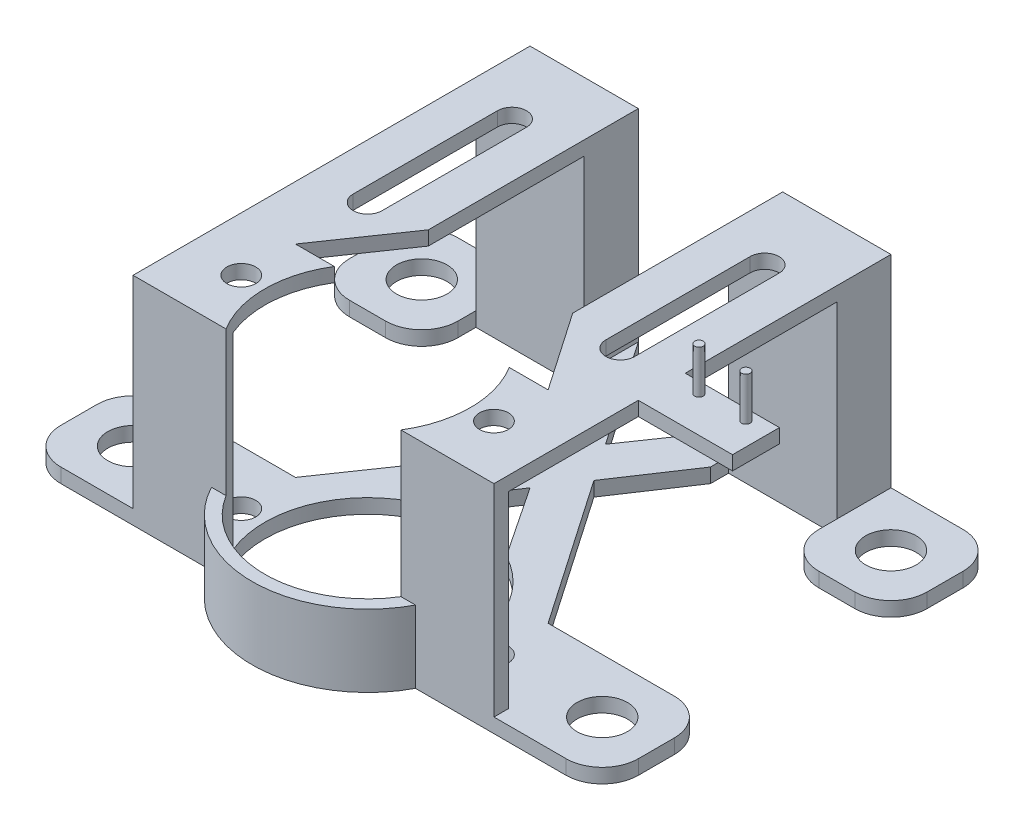
from build123d import *

# Parameters (mm, degrees)
SKETCH1_R             = 2
BOSS_EXTRUDE3_DEPTH   = 30
BOSS_EXTRUDE3_2_DEPTH = 30
SKETCH1_6_W           = 15
SKETCH1_6_H           = 15
SKETCH1_6_R           = 3.5
BOSS_EXTRUDE5_DEPTH   = 2
BOSS_EXTRUDE7_DEPTH   = 30
BOSS_EXTRUDE8_DEPTH   = 30
SKETCH6_W             = 28.26658805
SKETCH6_H             = 20
CUT_EXTRUDE2_DEPTH    = 9
SKETCH1_11_R          = 0.6
BOSS_EXTRUDE9_DEPTH   = 36
BOSS_EXTRUDE9_2_DEPTH = 36
SKETCH1_12_R          = 0.6
BOSS_EXTRUDE10_DEPTH  = 30
SKETCH8_W             = 13.05
SKETCH8_H             = 28.046654986
CUT_EXTRUDE3_DEPTH    = 7
CUT_EXTRUDE8_DEPTH    = 50
FILLET2_R             = 5
SKETCH11_W            = 12.973509336
SKETCH11_H            = 26.046654986
CUT_EXTRUDE9_DEPTH    = 52
BOSS_EXTRUDE11_DEPTH  = 2


with BuildPart() as part:
    # Sketch1 → Boss-Extrude3 (new body)
    with BuildSketch(Plane(origin=(0, 0, 0), x_dir=(1, 0, 0), z_dir=(0, 1, 0))):
        with BuildLine():
            Line((-15, 0), (-2.116620816, 0))
            ThreePointArc((-2.116620816, 0), (-3.706282257, 3.601240366), (-4.25, 7.5))
            ThreePointArc((-4.25, 7.5), (-3.706282257, 11.398759634), (-2.116620816, 15))
            Line((-2.116620816, 15), (-7.5, 15))
            Line((-7.5, 15), (0, 25.909090909))
            Line((0, 25.909090909), (0, 55))
            Line((0, 55), (-15, 55))
            Line((-15, 55), (-15, 0))
        make_face()
        with Locations((-7.5, 7.5)):
            Circle(SKETCH1_R, mode=Mode.SUBTRACT)
        with BuildLine():
            ThreePointArc((-9.5, 45), (-7.5, 47), (-5.5, 45))
            Line((-5.5, 45), (-5.5, 25))
            ThreePointArc((-5.5, 25), (-7.5, 23), (-9.5, 25))
            Line((-9.5, 25), (-9.5, 45))
        make_face(mode=Mode.SUBTRACT)
    extrude(amount=BOSS_EXTRUDE3_DEPTH)



with BuildPart() as body_2:
    # Sketch1 → Boss-Extrude3 2 (new body)
    with BuildSketch(Plane(origin=(0, 0, 0), x_dir=(1, 0, 0), z_dir=(0, 1, 0))):
        with BuildLine():
            ThreePointArc((22.116620816, 15), (23.706282257, 11.398759634), (24.25, 7.5))
            Line((24.25, 7.5), (25.5, 7.5))
            ThreePointArc((25.5, 7.5), (27.5, 9.5), (29.5, 7.5))
            Line((29.5, 7.5), (35, 7.5))
            Line((35, 7.5), (35, 55))
            Line((35, 55), (20, 55))
            Line((20, 55), (20, 25.909090909))
            Line((20, 25.909090909), (27.5, 15))
            Line((27.5, 15), (22.116620816, 15))
        make_face()
        with BuildLine():
            ThreePointArc((29.5, 25), (27.5, 23), (25.5, 25))
            Line((25.5, 25), (25.5, 45))
            ThreePointArc((25.5, 45), (27.5, 47), (29.5, 45))
            Line((29.5, 45), (29.5, 25))
        make_face(mode=Mode.SUBTRACT)
    extrude(amount=BOSS_EXTRUDE3_2_DEPTH)


with BuildPart() as part_1:
    add(part.part)

    add(body_2.part)  # Boss-Extrude5 merges body 2
    # Sketch1_6 → Boss-Extrude5 (add)
    # profile 1 of 4: a face of its own
    with BuildSketch(Plane(origin=(0, 0, 0), x_dir=(1, 0, 0), z_dir=(0, 1, 0))):
        with Locations((-22.5, 7.5)):
            Rectangle(SKETCH1_6_W, SKETCH1_6_H)
        with Locations((-22.5, 7.5)):
            Circle(SKETCH1_6_R, mode=Mode.SUBTRACT)
    # profile 2 of 4: a face of its own
    with BuildSketch(Plane(origin=(0, 0, 0), x_dir=(1, 0, 0), z_dir=(0, 1, 0))):
        with Locations((42.5, 7.5)):
            Rectangle(SKETCH1_6_W, SKETCH1_6_H)
        with Locations((42.5, 7.5)):
            Circle(SKETCH1_6_R, mode=Mode.SUBTRACT)
    # profile 3 of 4: a face of its own
    with BuildSketch(Plane(origin=(0, 0, 0), x_dir=(1, 0, 0), z_dir=(0, 1, 0))):
        with Locations((-22.5, 47.5)):
            Rectangle(SKETCH1_6_W, SKETCH1_6_H)
        with Locations((-22.5, 47.5)):
            Circle(SKETCH1_6_R, mode=Mode.SUBTRACT)
    # profile 4 of 4: a face of its own
    with BuildSketch(Plane(origin=(0, 0, 0), x_dir=(1, 0, 0), z_dir=(0, 1, 0))):
        with Locations((42.5, 47.5)):
            Rectangle(SKETCH1_6_W, SKETCH1_6_H)
        with Locations((42.5, 47.5)):
            Circle(SKETCH1_6_R, mode=Mode.SUBTRACT)
    extrude(amount=BOSS_EXTRUDE5_DEPTH)

    # Sketch1_8 → Boss-Extrude7 (add)
    with BuildSketch(Plane(origin=(0, 0, 0), x_dir=(1, 0, 0), z_dir=(0, 1, 0))):
        with BuildLine():
            Line((-2.116620816, 0), (-4.133294025, 0))
            ThreePointArc((-4.133294025, 0), (1.753788749, -6.211309201), (10, -8.5))
            ThreePointArc((10, -8.5), (18.246211251, -6.211309201), (24.133294025, 0))
            Line((24.133294025, 0), (22.116620816, 0))
            ThreePointArc((22.116620816, 0), (10, -6.75), (-2.116620816, 0))
        make_face()
    extrude(amount=BOSS_EXTRUDE7_DEPTH)

    # Sketch1_9 → Boss-Extrude8 (add)
    with BuildSketch(Plane(origin=(0, 0, 0), x_dir=(1, 0, 0), z_dir=(0, 1, 0))):
        with BuildLine():
            ThreePointArc((24.25, 7.5), (23.706282257, 3.601240366), (22.116620816, 0))
            Line((22.116620816, 0), (24.133294025, 0))
            Line((24.133294025, 0), (35, 0))
            Line((35, 0), (35, 7.5))
            Line((35, 7.5), (29.5, 7.5))
            ThreePointArc((29.5, 7.5), (27.5, 5.5), (25.5, 7.5))
            Line((25.5, 7.5), (24.25, 7.5))
        make_face()
    extrude(amount=BOSS_EXTRUDE8_DEPTH)

    # Sketch6 → Cut-Extrude2 (cut)
    with BuildSketch(Plane.XY):
        with Locations((10, 20)):
            Rectangle(SKETCH6_W, SKETCH6_H)
    extrude(amount=CUT_EXTRUDE2_DEPTH, mode=Mode.SUBTRACT)



with BuildPart() as body_2_2:
    # Sketch1_11 → Boss-Extrude9 (new body)
    with BuildSketch(Plane(origin=(0, 0, 0), x_dir=(1, 0, 0), z_dir=(0, 1, 0))):
        with Locations((44.9, 25)):
            Circle(SKETCH1_11_R)
    extrude(amount=BOSS_EXTRUDE9_DEPTH)


with BuildPart() as body_3:
    # Sketch1_11 → Boss-Extrude9 2 (new body)
    with BuildSketch(Plane(origin=(0, 0, 0), x_dir=(1, 0, 0), z_dir=(0, 1, 0))):
        with Locations((38.4, 25)):
            Circle(SKETCH1_11_R)
    extrude(amount=BOSS_EXTRUDE9_2_DEPTH)


with BuildPart() as part_2:
    add(part_1.part)

    add(body_2_2.part)  # Boss-Extrude10 merges body 2 2

    add(body_3.part)  # Boss-Extrude10 merges body 3
    # Sketch1_12 → Boss-Extrude10 (add)
    with BuildSketch(Plane(origin=(0, 0, 0), x_dir=(1, 0, 0), z_dir=(0, 1, 0))):
        Polygon((35, 26.5), (35, 20), (48.05, 20), (48.05, 26.5), (38.4, 26.5), align=None)
        with BuildLine():
            ThreePointArc((39, 25), (37.975735931, 24.575735931), (38.4, 25.6))
            ThreePointArc((38.4, 25.6), (38.824264069, 25.424264069), (39, 25))
        make_face(mode=Mode.SUBTRACT)
        with Locations((44.9, 25)):
            Circle(SKETCH1_12_R, mode=Mode.SUBTRACT)
    extrude(amount=BOSS_EXTRUDE10_DEPTH)

    # Sketch8 → Cut-Extrude3 (cut)
    with BuildSketch(Plane.XY.offset(-20)):
        with Locations((41.525, 14.023327493)):
            Rectangle(SKETCH8_W, SKETCH8_H)
    extrude(amount=-CUT_EXTRUDE3_DEPTH, mode=Mode.SUBTRACT)

    # Sketch10 → Cut-Extrude8 (cut)
    with BuildSketch(Plane(origin=(35, 0, 0), x_dir=(0, 0, -1), z_dir=(1, 0, 0))):
        Polygon((15, 2), (15, 0), (40, 0), (47.5, 0), (47.5, 28.046654986), (15, 28.046654986), align=None)
    extrude(amount=-CUT_EXTRUDE8_DEPTH, mode=Mode.SUBTRACT)

    # Fillet2
    fillet2_edges = [part_2.edges().sort_by_distance(p)[0] for p in [
        (-30, 1, -15),
        (-30, 1, -40),
        (-30, 1, -55),
        (-15, 1, -40),
        (-30, 1, 0),
        (50, 1, 0),
        (50, 1, -15),
        (35, 1, -40),
        (50, 1, -40),
        (50, 1, -55),
    ]]
    fillet(fillet2_edges, radius=FILLET2_R)

    # Sketch11 → Cut-Extrude9 (cut)
    with BuildSketch(Plane(origin=(35, 0, 0), x_dir=(0, 0, -1), z_dir=(1, 0, 0))):
        with Locations((8.513245332, 15.023327493)):
            Rectangle(SKETCH11_W, SKETCH11_H)
    extrude(amount=-CUT_EXTRUDE9_DEPTH, mode=Mode.SUBTRACT)

    # Sketch1_13 → Boss-Extrude11 (add)
    with BuildSketch(Plane(origin=(0, 0, 0), x_dir=(1, 0, 0), z_dir=(0, 1, 0))):
        with BuildLine():
            Line((-7.5, 15), (-2.116620816, 15))
            ThreePointArc((-2.116620816, 15), (0.309032182, 17.947374921), (3.43006352, 20.145095281))
            Line((3.43006352, 20.145095281), (10, 30))
            Line((10, 30), (16.56993648, 20.145095281))
            ThreePointArc((16.56993648, 20.145095281), (19.690967818, 17.947374921), (22.116620816, 15))
            Line((22.116620816, 15), (27.5, 15))
            Line((27.5, 15), (13.538461538, 35.307692308))
            Line((13.538461538, 35.307692308), (20, 45))
            Line((20, 45), (20, 55))
            Line((20, 55), (10, 40.454545455))
            Line((10, 40.454545455), (0, 55))
            Line((0, 55), (0, 45))
            Line((0, 45), (6.461538462, 35.307692308))
            Line((6.461538462, 35.307692308), (-7.5, 15))
        make_face()
    extrude(amount=BOSS_EXTRUDE11_DEPTH)


solid = part_2.part
